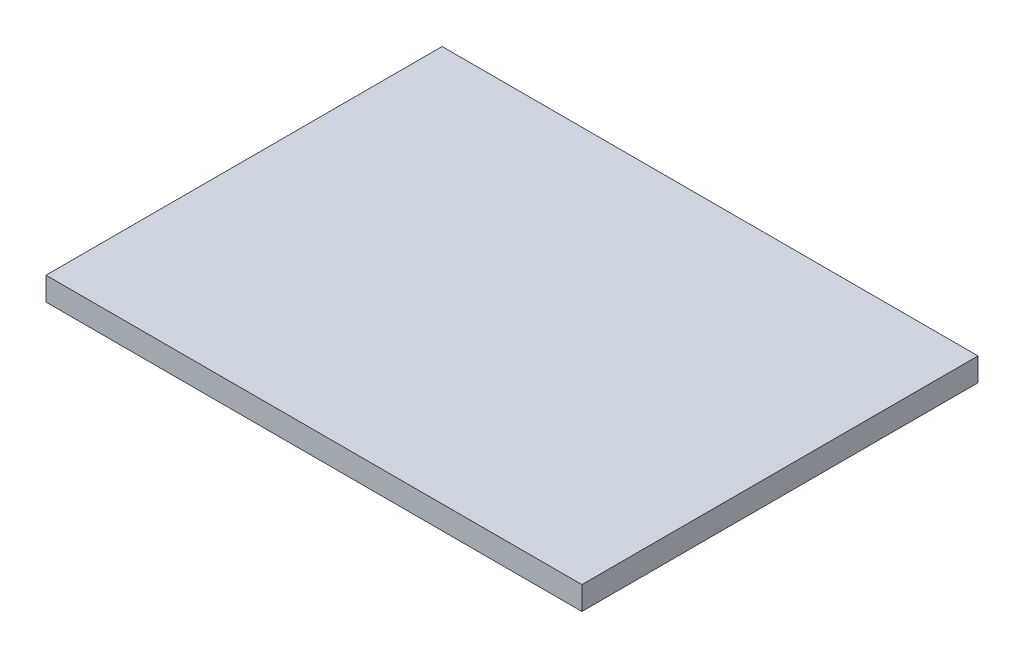
from build123d import *

# Parameters (mm, degrees)
ESQUISSE1_W        = 46
ESQUISSE1_H        = 34
BOSS_EXTRU_1_DEPTH = 2


with BuildPart() as part:
    # Esquisse1 → Boss.-Extru.1 (new body)
    with BuildSketch(Plane(origin=(0, 0, 0), x_dir=(1, 0, 0), z_dir=(0, 1, 0))):
        with Locations((23, 17)):
            Rectangle(ESQUISSE1_W, ESQUISSE1_H)
    extrude(amount=BOSS_EXTRU_1_DEPTH)


solid = part.part
